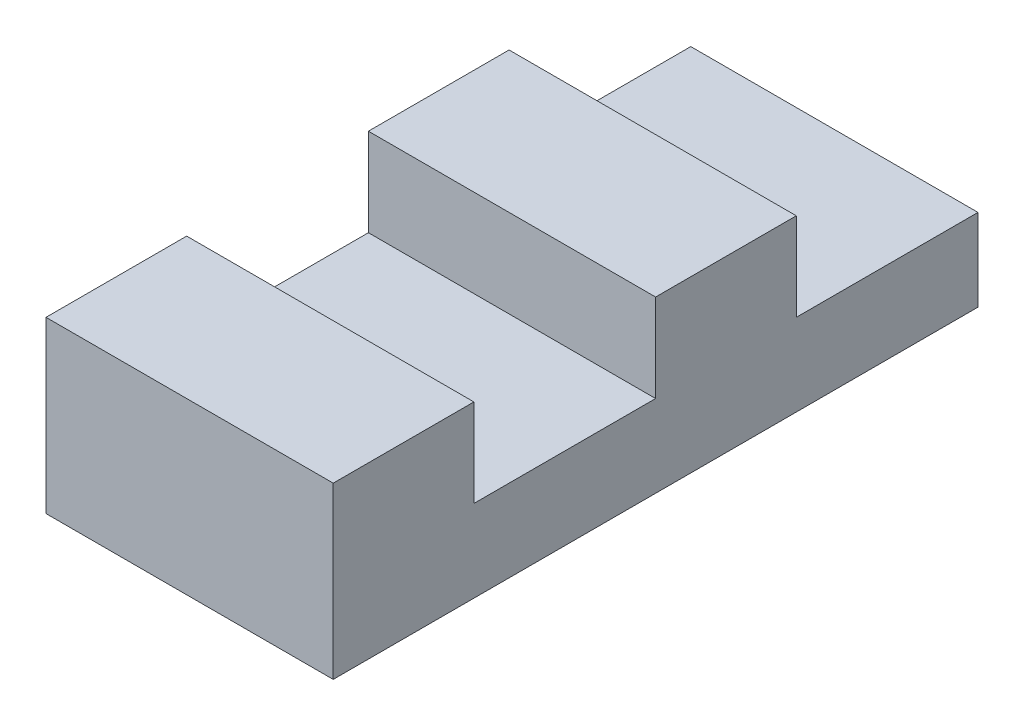
from build123d import *

# Parameters (mm, degrees)
BOSS_EXTRUDE1_DEPTH = 9.8
LPATTERN1_COUNT     = 2
LPATTERN1_PITCH     = 11


with BuildPart() as part:
    # Sketch1 → Boss-Extrude1 (new body)
    with BuildSketch(Plane(origin=(0, 0, 0), x_dir=(0, 0, -1), z_dir=(1, 0, 0))):
        Polygon((0, 0), (4.8, 0), (11, 0), (11, 2.8), (4.8, 2.8), (4.8, 5.8), (0, 5.8), align=None)
    boss_extrude1 = extrude(amount=BOSS_EXTRUDE1_DEPTH)

    # LPattern1: Boss-Extrude1 ×2
    with Locations(*[(0, 0, -i * LPATTERN1_PITCH) for i in range(1, LPATTERN1_COUNT)]):
        add(boss_extrude1)


solid = part.part
